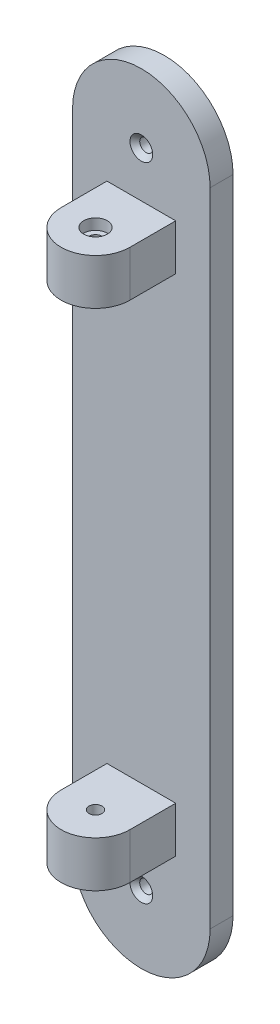
from build123d import *

# Parameters (mm, degrees)
BOSS_EXTRUDE1_DEPTH                             = 6.35
CSK_FOR_M3_FLAT_HEAD_MACHINE_SCREW1_D           = 3.6
CSK_FOR_M3_FLAT_HEAD_MACHINE_SCREW1_CSINK_D     = 6.3
CSK_FOR_M3_FLAT_HEAD_MACHINE_SCREW1_CSINK_ANGLE = 90
SKETCH3_W                                       = 19.05
SKETCH3_H                                       = 12.7
BOSS_EXTRUDE2_DEPTH                             = 12.7
BOSS_EXTRUDE5_DEPTH                             = 12.7
CBORE_FOR_M3_SHCS1_D                            = 3.6
CBORE_FOR_M3_SHCS1_CBORE_D                      = 6.5
CBORE_FOR_M3_SHCS1_CBORE_DEPTH                  = 3


with BuildPart() as part:
    # Sketch1 → Boss-Extrude1 (new body)
    with BuildSketch(Plane.XY):
        with BuildLine():
            Line((0, 0), (38.1, 0))
            Line((38.1, 0), (38.1, 88.9))
            ThreePointArc((38.1, 88.9), (19.05, 107.95), (0, 88.9))
            Line((0, 88.9), (0, 0))
        make_face()
    boss_extrude1 = extrude(amount=BOSS_EXTRUDE1_DEPTH)

    # CSK for M3 Flat Head Machine Screw1 (through all)
    with Locations(Plane(origin=(19.05, 88.9, 6.35), x_dir=(1, 0, 0), z_dir=(0, 0, 1))):
        with Locations((0, 0)):
            csk_for_m3_flat_head_machine_screw1 = CounterSinkHole(CSK_FOR_M3_FLAT_HEAD_MACHINE_SCREW1_D / 2, CSK_FOR_M3_FLAT_HEAD_MACHINE_SCREW1_CSINK_D / 2, counter_sink_angle=CSK_FOR_M3_FLAT_HEAD_MACHINE_SCREW1_CSINK_ANGLE)

    # Sketch3 → Boss-Extrude2 (add)
    with BuildSketch(Plane.XY.offset(6.35)):
        with Locations((19.05, 69.85)):
            Rectangle(SKETCH3_W, SKETCH3_H)
    boss_extrude2 = extrude(amount=BOSS_EXTRUDE2_DEPTH)

    # Sketch6 → Boss-Extrude5 (add)
    with BuildSketch(Plane(origin=(0, 76.2, 0), x_dir=(1, 0, 0), z_dir=(0, 1, 0))):
        with BuildLine():
            Line((9.525, -19.05), (28.575, -19.05))
            ThreePointArc((28.575, -19.05), (19.05, -28.575), (9.525, -19.05))
        make_face()
    boss_extrude5 = extrude(amount=-BOSS_EXTRUDE5_DEPTH)

    # CBORE for M3 SHCS1 (through all)
    with Locations(Plane(origin=(0, 76.2, 0), x_dir=(1, 0, 0), z_dir=(0, 1, 0))):
        with Locations((19.05, -19.05)):
            cbore_for_m3_shcs1 = CounterBoreHole(CBORE_FOR_M3_SHCS1_D / 2, CBORE_FOR_M3_SHCS1_CBORE_D / 2, CBORE_FOR_M3_SHCS1_CBORE_DEPTH)

    # Mirror1: Boss-Extrude1, CSK for M3 Flat Head Machine Screw1, Boss-Extrude2, Boss-Extrude5, CBORE for M3 SHCS1 across plane
    add(boss_extrude1.mirror(Plane.ZX))
    add(csk_for_m3_flat_head_machine_screw1.mirror(Plane.ZX), mode=Mode.SUBTRACT)
    add(boss_extrude2.mirror(Plane.ZX))
    add(boss_extrude5.mirror(Plane.ZX))
    add(cbore_for_m3_shcs1.mirror(Plane.ZX), mode=Mode.SUBTRACT)


solid = part.part
